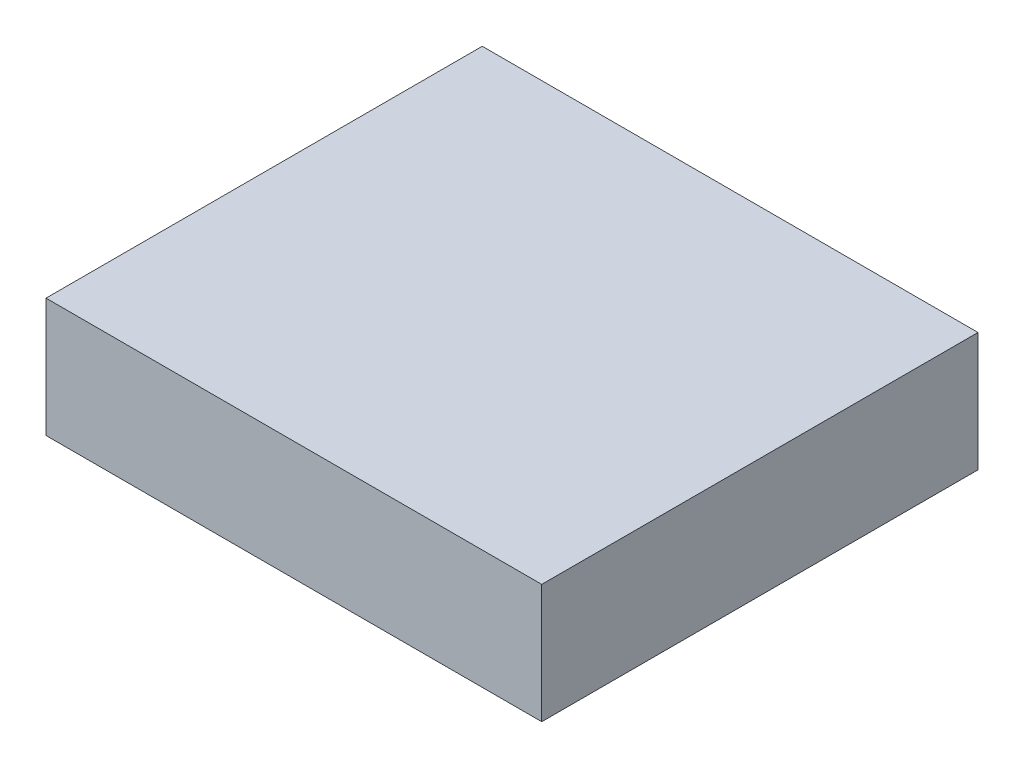
from build123d import *

# Parameters (mm, degrees)
SKETCH1_W           = 5
SKETCH1_H           = 4.4
BOSS_EXTRUDE1_DEPTH = 1.2


with BuildPart() as part:
    # Sketch1 → Boss-Extrude1 (new body)
    with BuildSketch(Plane(origin=(0, 0, 0), x_dir=(1, 0, 0), z_dir=(0, 1, 0))):
        Rectangle(SKETCH1_W, SKETCH1_H)
    extrude(amount=BOSS_EXTRUDE1_DEPTH)


solid = part.part
